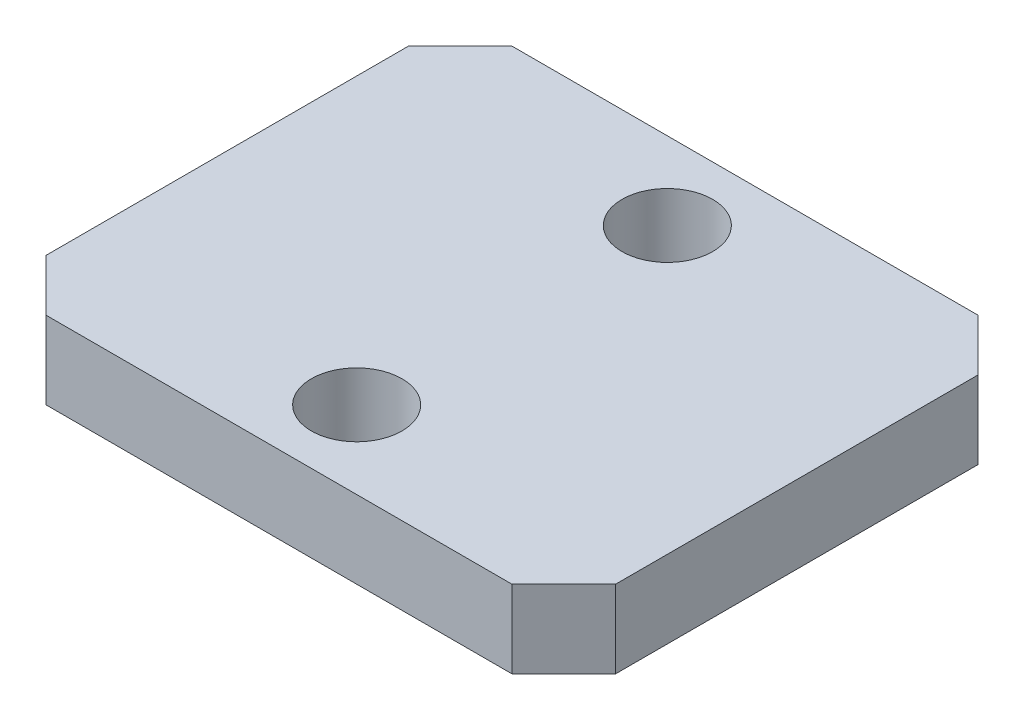
from build123d import *

# Parameters (mm, degrees)
SKETCH1_W                      = 22
SKETCH1_H                      = 18
BOSS_EXTRUDE1_DEPTH            = 3
CUT_EXTRUDE1_REACH             = 5
SKETCH2_R                      = 1.75
CUT_EXTRUDE1_DIRECTION_2_DEPTH = 1
CHAMFER1_SIZE                  = 2


with BuildPart() as part:
    # Sketch1 → Boss-Extrude1 (new body)
    with BuildSketch(Plane(origin=(0, 0, 0), x_dir=(1, 0, 0), z_dir=(0, 1, 0))):
        Rectangle(SKETCH1_W, SKETCH1_H)
    extrude(amount=BOSS_EXTRUDE1_DEPTH)

    # Sketch2 → Cut-Extrude1 (cut, up to next)
    with BuildSketch(Plane(origin=(0, 3, 0), x_dir=(1, 0, 0), z_dir=(0, 1, 0)), mode=Mode.PRIVATE) as cut_extrude1_sk1:
        with Locations((0, 6)):
            Circle(SKETCH2_R)
    cut_extrude1_tool1 = extrude(cut_extrude1_sk1.sketch, amount=-CUT_EXTRUDE1_REACH, mode=Mode.PRIVATE) & part.part
    add(cut_extrude1_tool1.solids().sort_by_distance((0, 3, -6))[0], mode=Mode.SUBTRACT)
    # Sketch2 → Cut-Extrude1 (cut, up to next)
    with BuildSketch(Plane(origin=(0, 3, 0), x_dir=(1, 0, 0), z_dir=(0, 1, 0)), mode=Mode.PRIVATE) as cut_extrude1_sk2:
        with Locations((0, -6)):
            Circle(SKETCH2_R)
    cut_extrude1_tool2 = extrude(cut_extrude1_sk2.sketch, amount=-CUT_EXTRUDE1_REACH, mode=Mode.PRIVATE) & part.part
    add(cut_extrude1_tool2.solids().sort_by_distance((0, 3, 6))[0], mode=Mode.SUBTRACT)

    # Sketch2 → Cut-Extrude1 direction 2 (cut)
    with BuildSketch(Plane(origin=(0, 3, 0), x_dir=(1, 0, 0), z_dir=(0, 1, 0))):
        with Locations((0, 6)):
            Circle(SKETCH2_R)
        with Locations((0, -6)):
            Circle(SKETCH2_R)
    extrude(amount=CUT_EXTRUDE1_DIRECTION_2_DEPTH, mode=Mode.SUBTRACT)

    # Chamfer1
    chamfer1_edges = [part.edges().sort_by_distance(p)[0] for p in [
        (11, 1.5, 9),
        (-11, 1.5, 9),
        (-11, 1.5, -9),
        (11, 1.5, -9),
    ]]
    chamfer(chamfer1_edges, length=CHAMFER1_SIZE)


solid = part.part
